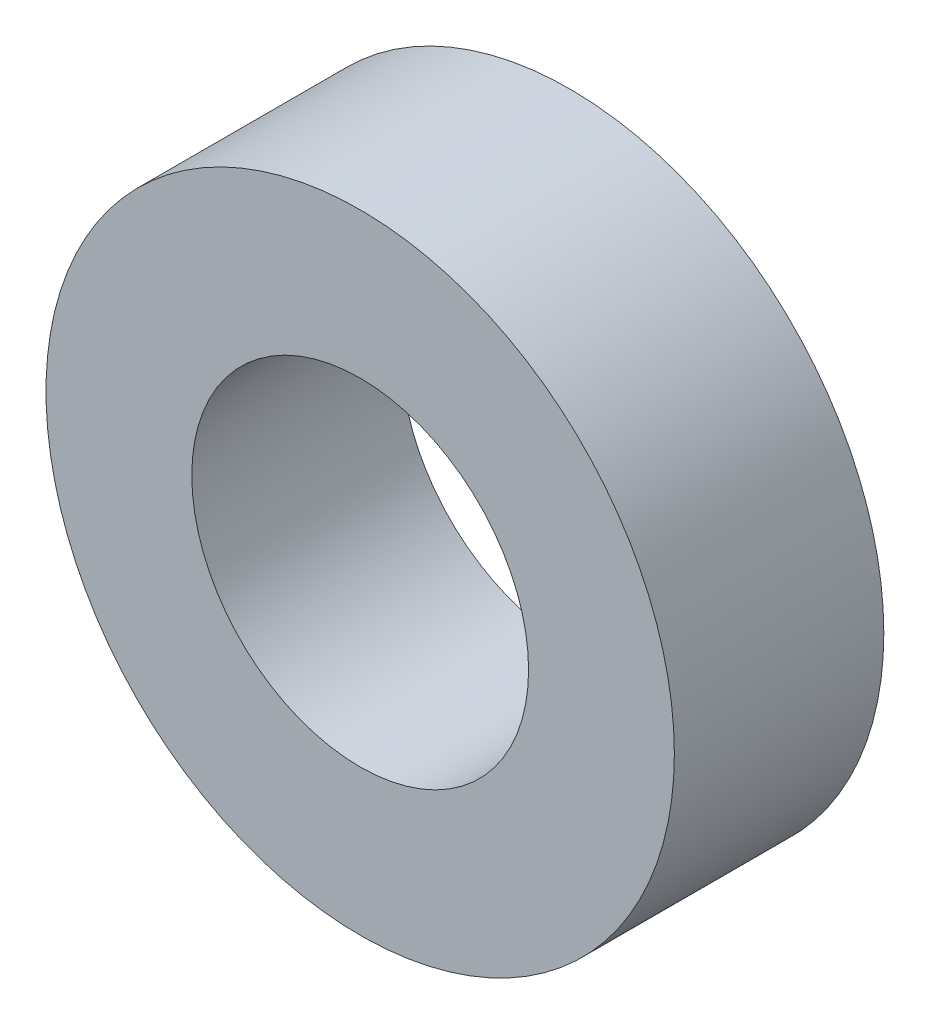
from build123d import *

# Parameters (mm, degrees)
SKETCH1_R           = 4.7625
SKETCH1_R_2         = 2.5527
BOSS_EXTRUDE1_DEPTH = 3.175


with BuildPart() as part:
    # Sketch1 → Boss-Extrude1 (new body)
    with BuildSketch(Plane.XY):
        Circle(SKETCH1_R)
        Circle(SKETCH1_R_2, mode=Mode.SUBTRACT)
    extrude(amount=BOSS_EXTRUDE1_DEPTH)


solid = part.part
